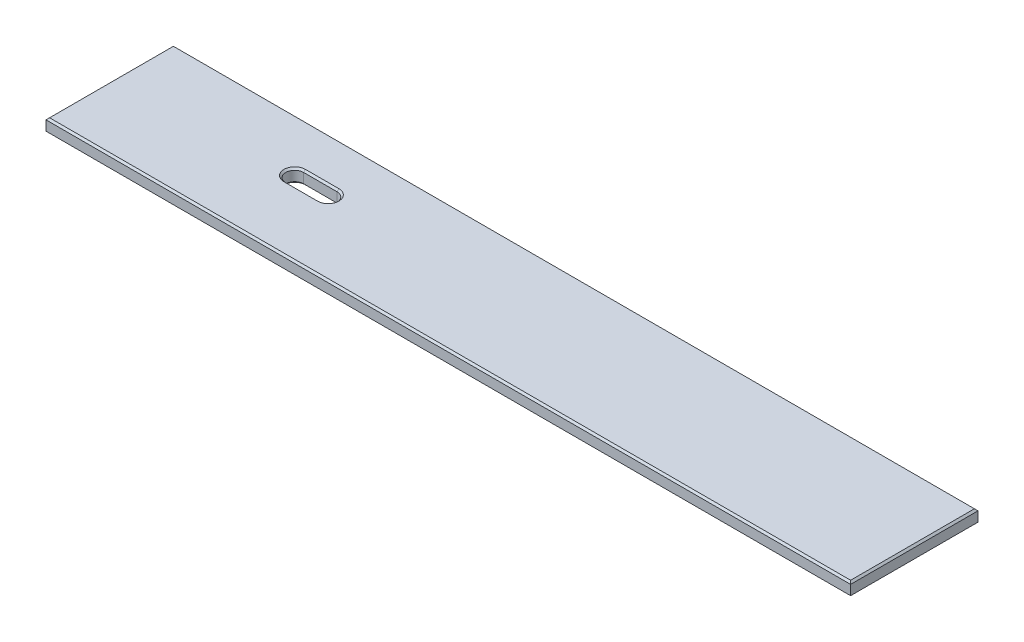
from build123d import *

# Parameters (mm, degrees)
SKETCH1_W           = 1143
SKETCH1_H           = 180.975
BOSS_EXTRUDE1_DEPTH = 19.05
CHAMFER1_SIZE       = 2.54
CHAMFER2_SIZE       = 2.54


with BuildPart() as part:
    # Sketch1 → Boss-Extrude1 (new body)
    with BuildSketch(Plane(origin=(0, 0, 0), x_dir=(1, 0, 0), z_dir=(0, 1, 0))):
        with Locations((571.5, 90.4875)):
            Rectangle(SKETCH1_W, SKETCH1_H)
        with BuildLine():
            Line((247.7262, 118.25605), (295.2877, 118.25605))
            ThreePointArc((295.2877, 118.25605), (307.9877, 105.55605), (295.2877, 92.85605))
            Line((295.2877, 92.85605), (247.7262, 92.85605))
            ThreePointArc((247.7262, 92.85605), (235.0262, 105.55605), (247.7262, 118.25605))
        make_face(mode=Mode.SUBTRACT)
    extrude(amount=BOSS_EXTRUDE1_DEPTH)

    # Chamfer1
    chamfer1_edges = [part.edges().sort_by_distance(p)[0] for p in [
        (1143, 19.05, -90.4875),
        (307.9877, 19.05, -105.55605),
        (571.5, 19.05, -180.975),
        (271.50695, 19.05, -118.25605),
        (235.0262, 19.05, -105.55605),
        (271.50695, 19.05, -92.85605),
        (0, 19.05, -90.4875),
        (571.5, 19.05, 0),
    ]]
    chamfer(chamfer1_edges, length=CHAMFER1_SIZE)

    # Chamfer2
    chamfer2_edges = [part.edges().sort_by_distance(p)[0] for p in [
        (307.9877, 0, -105.55605),
        (271.50695, 0, -118.25605),
        (235.0262, 0, -105.55605),
        (271.50695, 0, -92.85605),
        (571.5, 0, -180.975),
        (1143, 0, -90.4875),
        (571.5, 0, 0),
        (0, 0, -90.4875),
    ]]
    chamfer(chamfer2_edges, length=CHAMFER2_SIZE)


solid = part.part
